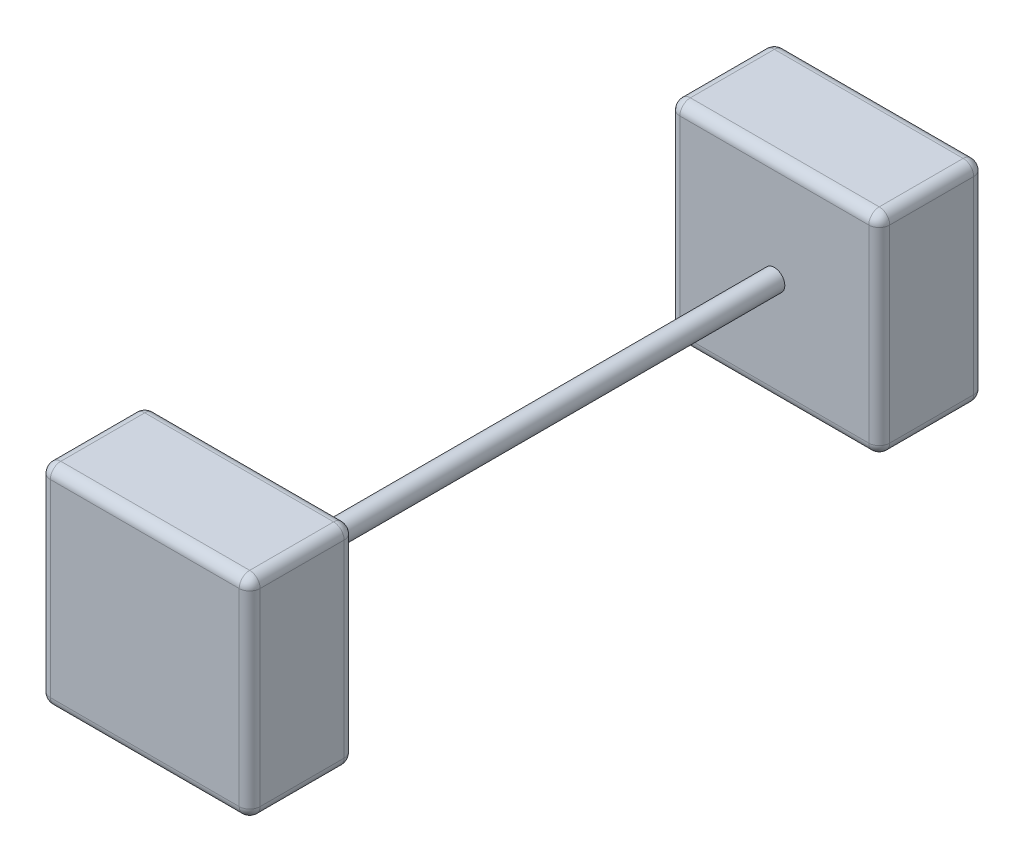
from build123d import *

# Parameters (mm, degrees)
SKETCH1_W           = 20
SKETCH1_H           = 20
BOSS_EXTRUDE1_DEPTH = 10
SKETCH4_W           = 20
SKETCH4_H           = 10
BOSS_EXTRUDE2_DEPTH = 20
FILLET6_R           = 1
FILLET7_R           = 1
SKETCH6_R           = 1
BOSS_EXTRUDE3_DEPTH = 60


with BuildPart() as part:
    # Sketch1 → Boss-Extrude1 (new body)
    with BuildSketch(Plane.XY):
        with Locations((10, 10)):
            Rectangle(SKETCH1_W, SKETCH1_H)
    extrude(amount=BOSS_EXTRUDE1_DEPTH)

    # Fillet6
    fillet6_edges = [part.edges().sort_by_distance(p)[0] for p in [
        (20, 10, 10),
        (10, 20, 10),
        (0, 10, 10),
        (10, 20, 0),
        (20, 10, 0),
        (10, 0, 0),
        (0, 10, 0),
        (0, 20, 5),
        (20, 20, 5),
        (20, 0, 5),
        (0, 0, 5),
        (10, 0, 10),
    ]]
    fillet(fillet6_edges, radius=FILLET6_R)



with BuildPart() as body_2:
    # Sketch4 → Boss-Extrude2 (new body)
    with BuildSketch(Plane(origin=(0, 0, 0), x_dir=(1, 0, 0), z_dir=(0, 1, 0))):
        with Locations((10, -65)):
            Rectangle(SKETCH4_W, SKETCH4_H)
    extrude(amount=BOSS_EXTRUDE2_DEPTH)

    # Fillet7
    fillet7_edges = [body_2.edges().sort_by_distance(p)[0] for p in [
        (20, 20, 65),
        (10, 20, 60),
        (0, 20, 65),
        (10, 0, 60),
        (20, 0, 65),
        (10, 0, 70),
        (0, 0, 65),
        (0, 10, 60),
        (20, 10, 60),
        (20, 10, 70),
        (0, 10, 70),
        (10, 20, 70),
    ]]
    fillet(fillet7_edges, radius=FILLET7_R)


with BuildPart() as part_1:
    add(part.part)

    add(body_2.part)  # Boss-Extrude3 merges body 2
    # Sketch6 → Boss-Extrude3 (add)
    with BuildSketch(Plane.XY.offset(10)):
        with Locations((10, 10)):
            Circle(SKETCH6_R)
    extrude(amount=BOSS_EXTRUDE3_DEPTH)


solid = part_1.part
